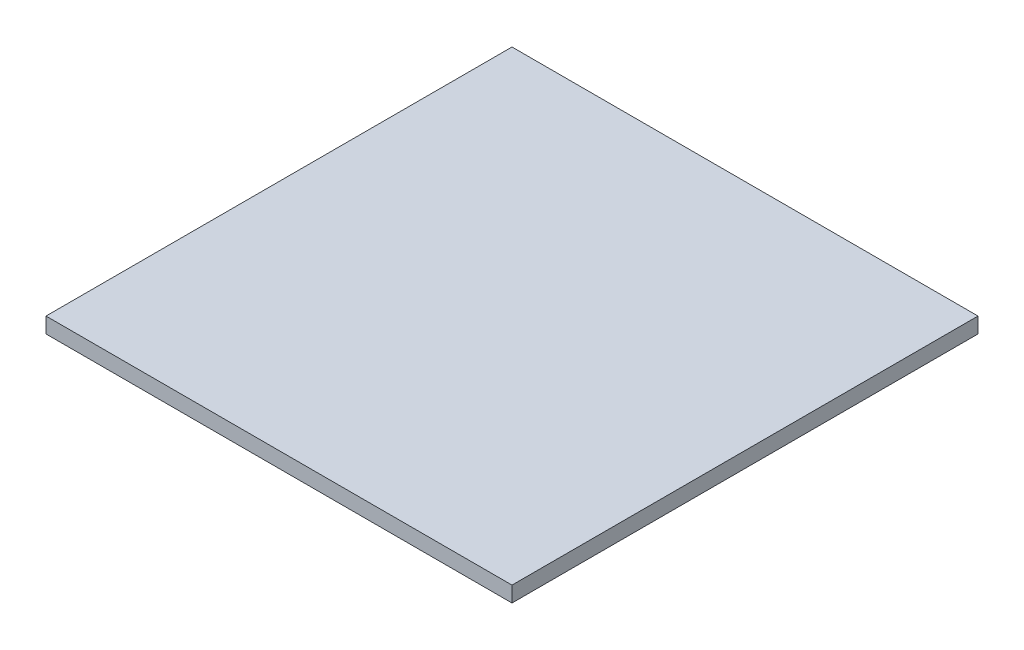
from build123d import *

# Parameters (mm, degrees)
SKETCH1_W           = 90
SKETCH1_H           = 90
BOSS_EXTRUDE1_DEPTH = 3


with BuildPart() as part:
    # Sketch1 → Boss-Extrude1 (new body)
    with BuildSketch(Plane(origin=(0, 0, 0), x_dir=(1, 0, 0), z_dir=(0, 1, 0))):
        with Locations((-1.146010187, -9.091680815)):
            Rectangle(SKETCH1_W, SKETCH1_H)
    extrude(amount=BOSS_EXTRUDE1_DEPTH)


solid = part.part
